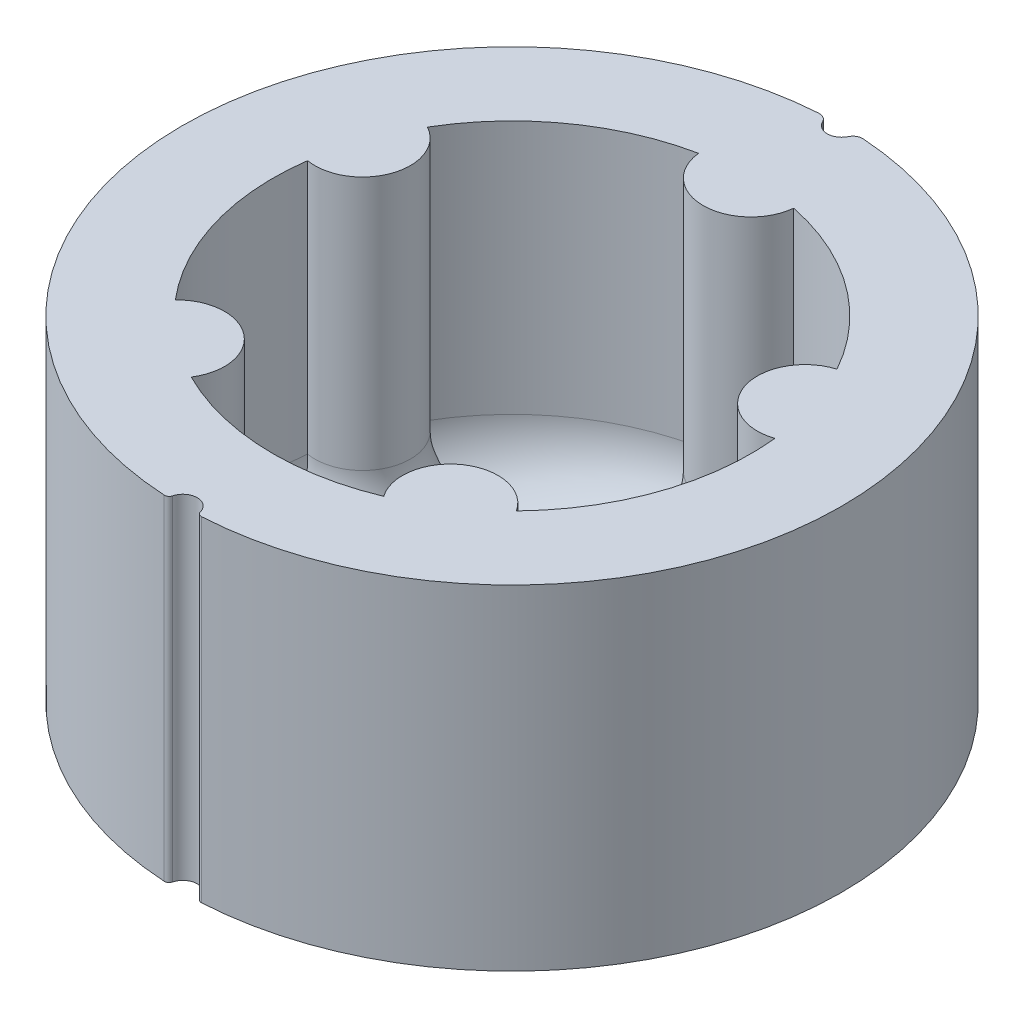
from build123d import *

# Parameters (mm, degrees)
BOSS_EXTRUDE1_DEPTH = 35
CUT_EXTRUDE2_DEPTH  = 61.012997416
BOSS_EXTRUDE2_DEPTH = 0.4
FILLET1_R           = 8


with BuildPart() as part:
    # Sketch1 → Boss-Extrude1 (new body)
    with BuildSketch(Plane(origin=(0, 0, 0), x_dir=(1, 0, 0), z_dir=(0, 1, 0))):
        with BuildLine():
            ThreePointArc((1.451818925, -34.068556857), (1.641248992, -34.346908706), (1.964225605, -34.442038138))
            ThreePointArc((1.964225605, -34.442038138), (26.591847487, -21.978073076), (34.198225299, 4.555174015))
            ThreePointArc((34.198225299, 4.555174015), (23.590291339, 25.176355888), (2.324135821, 34.423627607))
            ThreePointArc((2.324135821, 34.423627607), (1.751838249, 34.289058819), (1.354061739, 33.856153382))
            ThreePointArc((1.354061739, 33.856153382), (0, 33.001534515), (-1.354061739, 33.856153382))
            ThreePointArc((-1.354061739, 33.856153382), (-1.751838249, 34.289058819), (-2.324135821, 34.423627607))
            ThreePointArc((-2.324135821, 34.423627607), (-23.590291339, 25.176355888), (-34.198225299, 4.555174015))
            ThreePointArc((-34.198225299, 4.555174015), (-26.591847487, -21.978073076), (-1.964225605, -34.442038138))
            ThreePointArc((-1.964225605, -34.442038138), (-1.641248992, -34.346908706), (-1.451818925, -34.068556857))
            ThreePointArc((-1.451818925, -34.068556857), (0, -32.945679925), (1.451818925, -34.068556857))
        make_face()
        with BuildLine():
            Line((-2.417, 3.787737139), (0, 3.787737139))
            Line((0, 3.787737139), (2.417, 3.787737139))
            ThreePointArc((2.417, 3.787737139), (0, -4.489512172), (-2.417, 3.787737139))
        make_face(mode=Mode.SUBTRACT)
    extrude(amount=BOSS_EXTRUDE1_DEPTH)

    # Sketch2 → Cut-Extrude2 (cut, through all)
    with BuildSketch(Plane(origin=(0, 0, 0), x_dir=(1, 0, 0), z_dir=(0, 1, 0))):
        with BuildLine():
            ThreePointArc((-24.771875163, 3.369599515), (-23.997809329, -7.007506505), (-19.066036357, -16.170536714))
            ThreePointArc((-19.066036357, -16.170536714), (-12.361903527, -15.700472812), (-11.245933621, -22.327762472))
            ThreePointArc((-11.245933621, -22.327762472), (-0.884127319, -24.984361486), (9.639544373, -23.066841662))
            ThreePointArc((9.639544373, -23.066841662), (10.917339043, -16.055130989), (17.907795118, -17.44450842))
            ThreePointArc((17.907795118, -17.44450842), (23.625967237, -8.17396306), (24.859344713, 2.64820325))
            ThreePointArc((24.859344713, 2.64820325), (18.515062391, 5.879189473), (21.833190005, 12.178333803))
            ThreePointArc((21.833190005, 12.178333803), (14.752111216, 20.18353821), (4.974937186, 24.5))
            ThreePointArc((4.974937186, 24.5), (0, 20), (-4.974937186, 24.5))
            ThreePointArc((-4.974937186, 24.5), (-14.514359509, 20.355180374), (-21.541517866, 12.687119769))
            ThreePointArc((-21.541517866, 12.687119769), (-19.215771141, 6.662052225), (-24.771875163, 3.369599515))
        make_face()
    extrude(amount=CUT_EXTRUDE2_DEPTH, mode=Mode.SUBTRACT)

    # Sketch2_2 → Boss-Extrude2 (add)
    with BuildSketch(Plane(origin=(0, 0, 0), x_dir=(1, 0, 0), z_dir=(0, 1, 0))):
        with BuildLine():
            ThreePointArc((-24.771875163, 3.369599515), (-23.997809329, -7.007506505), (-19.066036357, -16.170536714))
            ThreePointArc((-19.066036357, -16.170536714), (-12.361903527, -15.700472812), (-11.245933621, -22.327762472))
            ThreePointArc((-11.245933621, -22.327762472), (-0.884127319, -24.984361486), (9.639544373, -23.066841662))
            ThreePointArc((9.639544373, -23.066841662), (10.917339043, -16.055130989), (17.907795118, -17.44450842))
            ThreePointArc((17.907795118, -17.44450842), (23.625967237, -8.17396306), (24.859344713, 2.64820325))
            ThreePointArc((24.859344713, 2.64820325), (18.515062391, 5.879189473), (21.833190005, 12.178333803))
            ThreePointArc((21.833190005, 12.178333803), (14.752111216, 20.18353821), (4.974937186, 24.5))
            ThreePointArc((4.974937186, 24.5), (0, 20), (-4.974937186, 24.5))
            ThreePointArc((-4.974937186, 24.5), (-14.514359509, 20.355180374), (-21.541517866, 12.687119769))
            ThreePointArc((-21.541517866, 12.687119769), (-19.215771141, 6.662052225), (-24.771875163, 3.369599515))
        make_face()
    extrude(amount=BOSS_EXTRUDE2_DEPTH)

    # Fillet1
    fillet1_edges = [part.edges().sort_by_distance(p)[0] for p in [
        (18.515062391, 0.4, -5.879189473),
        (23.625967237, 0.4, 8.17396306),
        (10.917339043, 0.4, 16.055130989),
        (-0.884127319, 0.4, 24.984361486),
        (-12.361903527, 0.4, 15.700472812),
        (-23.997809329, 0.4, 7.007506505),
        (-19.215771141, 0.4, -6.662052225),
        (-14.514359509, 0.4, -20.355180374),
        (0, 0.4, -20),
        (14.752111216, 0.4, -20.18353821),
    ]]
    fillet(fillet1_edges, radius=FILLET1_R)


solid = part.part
